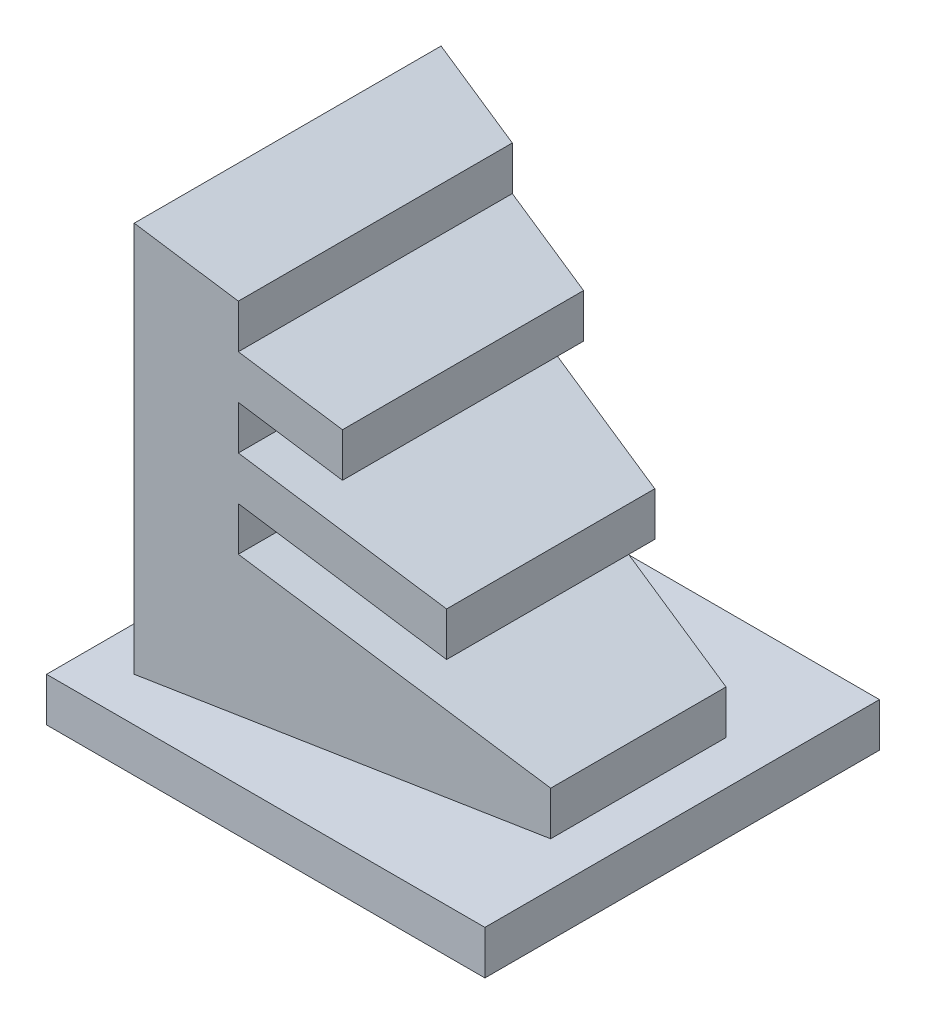
from build123d import *

# Parameters (mm, degrees)
SKETCH1_W      = 100
SKETCH1_H      = 90
EXTRUDE1_DEPTH = 10
EXTRUDE2_DEPTH = 89.118
EXTRUDE3_DEPTH = 64.559


with BuildPart() as part:
    # Sketch1 → Extrude1 (new body)
    with BuildSketch(Plane(origin=(0, 0, 0), x_dir=(1, 0, 0), z_dir=(0, 1, 0))):
        with Locations((-40, 20)):
            Rectangle(SKETCH1_W, SKETCH1_H)
    extrude(amount=EXTRUDE1_DEPTH)

    # Sketch2 → Extrude2 (add)
    with BuildSketch(Plane(origin=(0, 10, 0), x_dir=(1, 0, 0), z_dir=(0, 1, 0))):
        Polygon((0, 0), (0, 40), (-80, 55), (-80, -15), align=None)
    extrude(amount=EXTRUDE2_DEPTH)

    # Sketch3 → Extrude3 (cut, symmetric)
    with BuildSketch(Plane.XY):
        Polygon((0, 99.118), (-80, 99.118), (-60, 91.838595315), (-60, 81.838595315), (-40, 74.559190629), (-40, 64.559190629), (-60, 71.838595315), (-60, 61.838595315), (-20, 47.279785944), (-20, 37.279785944), (-60, 51.838595315), (-60, 41.838595315), (0, 20.000381259), (0, 30.000381259), align=None)
    extrude(amount=EXTRUDE3_DEPTH, both=True, mode=Mode.SUBTRACT)


solid = part.part
